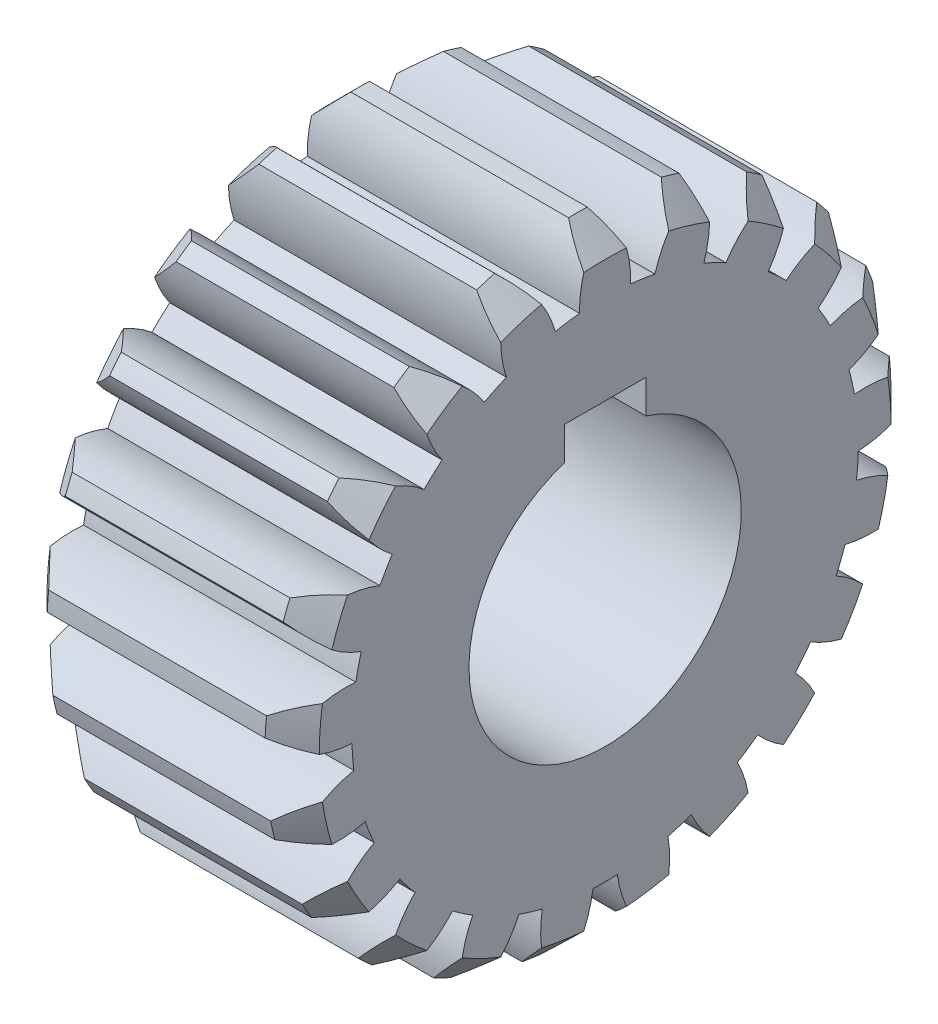
from build123d import *

# Parameters (mm, degrees)
SKETCH_1_W               = 20
SKETCH_1_H               = 13
CHAMFER_1_SIZE           = 2
CUT_EXTRUDE1_DEPTH       = 50
CIRPATTERN2_COUNT        = 21
SKETCH_2_W               = 6
SKETCH_2_H               = 12
CUT_EXTRUDE_1_DEPTH      = 11.0000001
CUT_EXTRUDE_1_DEPTH_BACK = 11.0000001


with BuildPart() as part:
    # Эскиз1 → Повернуть1 (revolve)
    with BuildSketch(Plane.XY):
        with Locations((0, 16.5)):
            Rectangle(SKETCH_1_W, SKETCH_1_H)
    revolve(axis=Axis((0, 0, 0), (-1, 0, 0)))

    # Фаска1
    chamfer_1_edges = [part.edges().sort_by_distance(p)[0] for p in [
        (-10, -23, 0),
        (10, -23, 0),
    ]]
    chamfer(chamfer_1_edges, length=CHAMFER_1_SIZE)

    # Sketch3 → Cut-Extrude1-Впадина зуба (cut)
    with BuildSketch(Plane(origin=(10, 9.497828625, -4.336443521), x_dir=(0, 0, -1), z_dir=(1, 0, 0))):
        with BuildLine():
            ThreePointArc((-2.454710786, 9.006740592), (-2.737020457, 11.333652448), (-3.651300225, 13.491964298))
            ThreePointArc((-3.651300225, 13.491964298), (-0.908471399, 13.245280378), (1.785212599, 12.672541835))
            ThreePointArc((1.785212599, 12.672541835), (0.275378131, 10.879606417), (-0.680258624, 8.739284962))
            ThreePointArc((-0.680258624, 8.739284962), (-1.564257371, 8.894424743), (-2.454710786, 9.006740592))
        make_face()
    cut_extrude1 = extrude(amount=-CUT_EXTRUDE1_DEPTH, mode=Mode.SUBTRACT)

    # CirPattern2: Cut-Extrude1-Впадина зуба ×21 about axis
    cirpattern2_axis = Axis((0, 0, 0), (1, 0, 0))
    for i in range(1, CIRPATTERN2_COUNT):
        add(cut_extrude1.rotate(cirpattern2_axis, i * 360 / CIRPATTERN2_COUNT), mode=Mode.SUBTRACT)

    # Эскиз2 → Вырез-Вытянуть1 (cut, two sides)
    with BuildSketch(Plane(origin=(0, 0, 0), x_dir=(0, 0, -1), z_dir=(1, 0, 0))) as cut_extrude_1_sk:
        with Locations((0, 6)):
            Rectangle(SKETCH_2_W, SKETCH_2_H)
    extrude(amount=CUT_EXTRUDE_1_DEPTH, mode=Mode.SUBTRACT)
    extrude(cut_extrude_1_sk.sketch, amount=-CUT_EXTRUDE_1_DEPTH_BACK, mode=Mode.SUBTRACT)


solid = part.part
